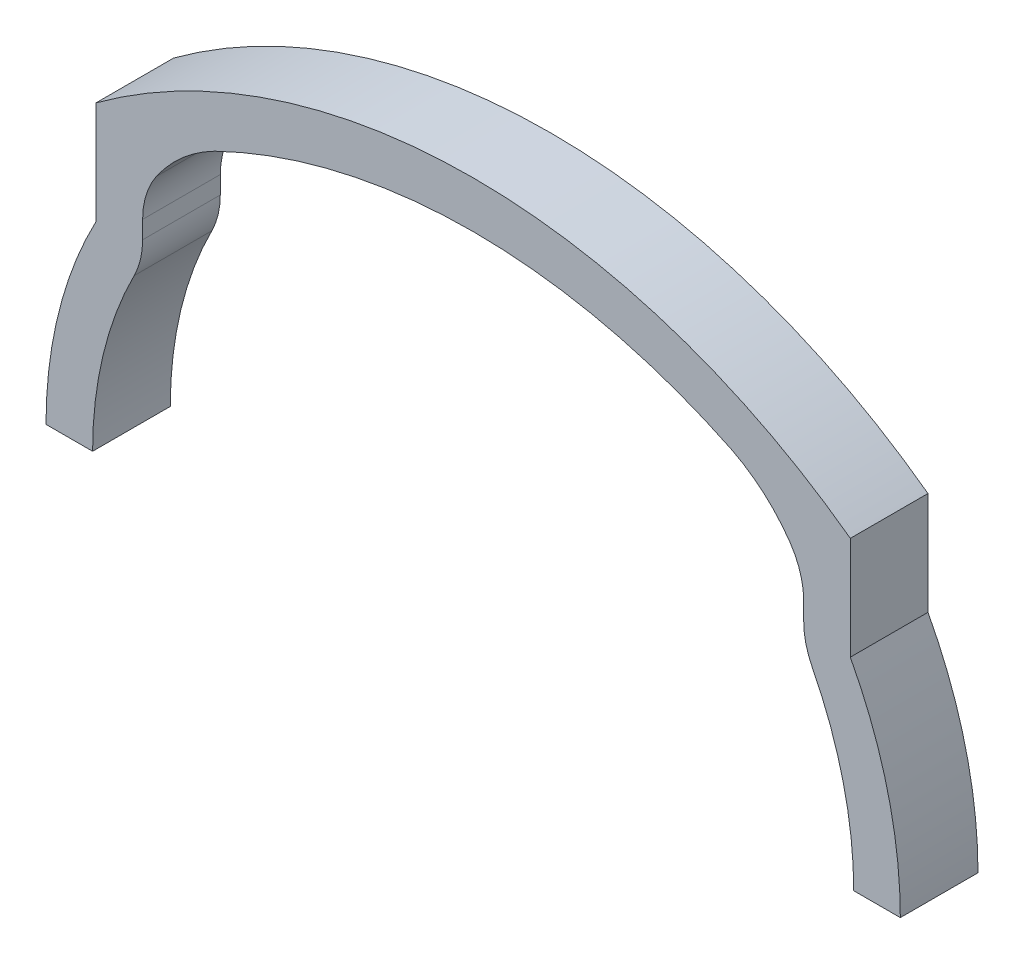
from build123d import *

# Parameters (mm, degrees)
BOSS_EXTRUDE3_DEPTH = 5


with BuildPart() as part:
    # Sketch1 → Boss-Extrude3 (new body)
    with BuildSketch(Plane.XY):
        with BuildLine():
            Line((-27.5, 0), (-24.5, 0))
            ThreePointArc((-24.5, 0), (-23.822061062, 5.723583386), (-21.825762712, 11.130412483))
            ThreePointArc((-21.825762712, 11.130412483), (-21.418354885, 12.233846993), (-21.28, 13.401925235))
            Line((-21.28, 13.401925235), (-21.28, 14.540127049))
            ThreePointArc((-21.28, 14.540127049), (-21.053037703, 16.029459479), (-20.392755565, 17.383582985))
            ThreePointArc((-20.392755565, 17.383582985), (-18.722329772, 19.255294032), (-16.644357741, 20.660874629))
            ThreePointArc((-16.644357741, 20.660874629), (0, 24.5), (16.644357741, 20.660874629))
            ThreePointArc((16.644357741, 20.660874629), (18.722329772, 19.255294032), (20.392755565, 17.383582985))
            ThreePointArc((20.392755565, 17.383582985), (21.053037703, 16.029459479), (21.28, 14.540127049))
            Line((21.28, 14.540127049), (21.28, 13.401925235))
            ThreePointArc((21.28, 13.401925235), (21.418354885, 12.233846993), (21.825762712, 11.130412483))
            ThreePointArc((21.825762712, 11.130412483), (23.822061062, 5.723583386), (24.5, 0))
            Line((24.5, 0), (27.5, 0))
            ThreePointArc((27.5, 0), (26.682859667, 6.653946198), (24.28, 12.9124591))
            Line((24.28, 12.9124591), (24.28, 19.537578604))
            ThreePointArc((24.28, 19.537578604), (0, 27.5), (-24.28, 19.537578604))
            Line((-24.28, 19.537578604), (-24.28, 12.9124591))
            ThreePointArc((-24.28, 12.9124591), (-26.682859667, 6.653946198), (-27.5, 0))
        make_face()
    extrude(amount=BOSS_EXTRUDE3_DEPTH)


solid = part.part
